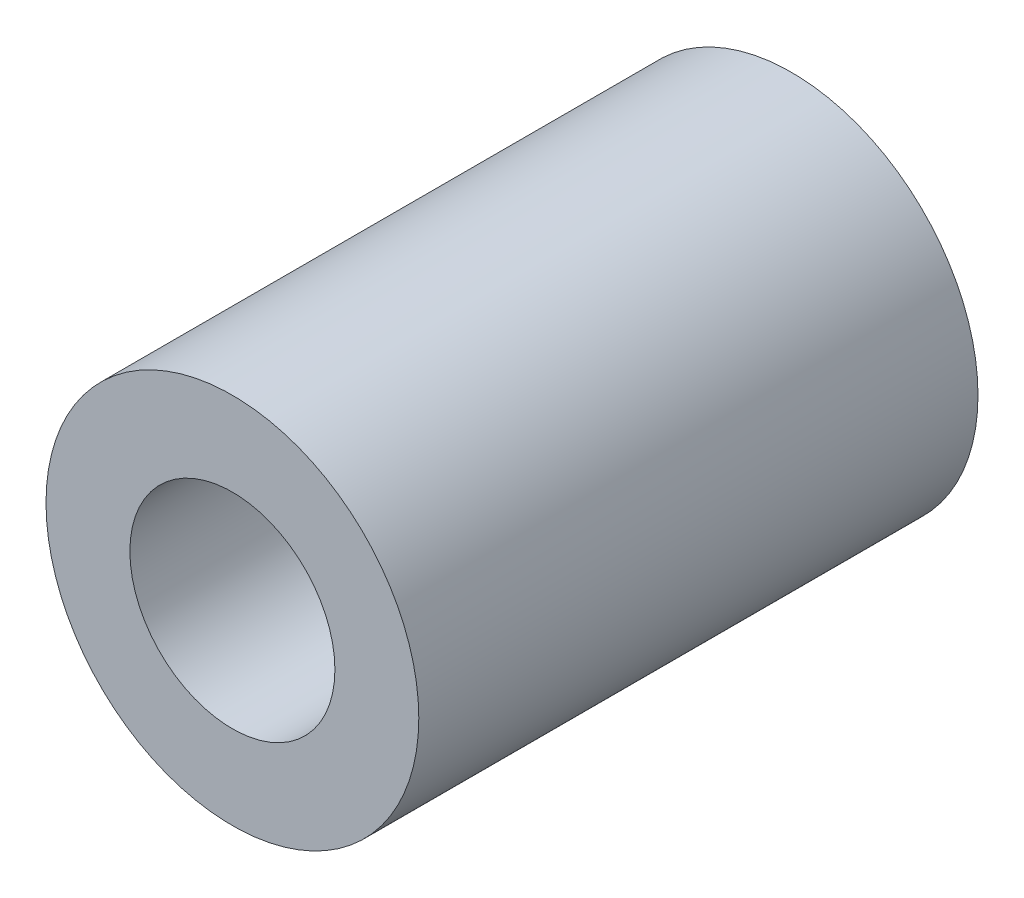
from build123d import *

# Parameters (mm, degrees)
ESQUISSE1_R        = 2
ESQUISSE1_R_2      = 1.1
BOSS_EXTRU_1_DEPTH = 6


with BuildPart() as part:
    # Esquisse1 → Boss.-Extru.1 (new body)
    with BuildSketch(Plane.XY):
        Circle(ESQUISSE1_R)
        Circle(ESQUISSE1_R_2, mode=Mode.SUBTRACT)
    extrude(amount=BOSS_EXTRU_1_DEPTH)


solid = part.part
